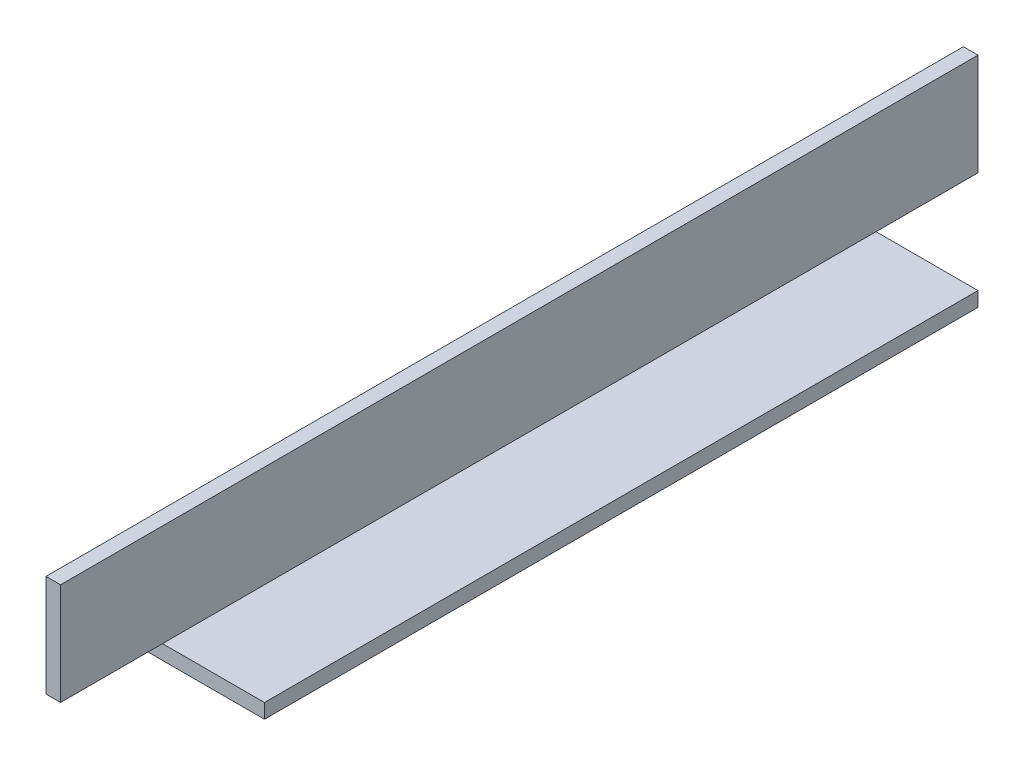
from build123d import *

# Parameters (mm, degrees)
BOSS_EXTRUDE1_DEPTH = 1219.2
FILLET1_R           = 0.4064
SKETCH4_W           = 2238.4
SKETCH4_H           = 103.278519729
CUT_EXTRUDE1_DEPTH  = 60
SKETCH5_W           = 25.4
SKETCH5_H           = 22.23
CUT_EXTRUDE2_DEPTH  = 3.175
SKETCH6_W           = 25.4
SKETCH6_H           = 22.23
CUT_EXTRUDE3_DEPTH  = 3.175
SKETCH7_W           = 1.26890891
SKETCH7_H           = 1.024965533
CUT_EXTRUDE4_DEPTH  = 220


with BuildPart() as part:
    # Sketch3 → Boss-Extrude1 (new, symmetric)
    with BuildSketch(Plane.XY):
        Polygon((3.175, 25.4), (0, 25.4), (0, 0), (25.4, 0), (25.4, 3.175), (3.175, 3.175), align=None)
    extrude(amount=BOSS_EXTRUDE1_DEPTH, both=True)

    # Fillet1
    fillet1_edges = [part.edges().sort_by_distance(p)[0] for p in [
        (3.175, 3.175, 0),
    ]]
    fillet(fillet1_edges, radius=FILLET1_R)

    # Sketch4 → Cut-Extrude1 (cut)
    with BuildSketch(Plane.ZY):
        with Locations((-100, -26.239259864)):
            Rectangle(SKETCH4_W, SKETCH4_H)
    extrude(amount=-CUT_EXTRUDE1_DEPTH, mode=Mode.SUBTRACT)

    # Sketch5 → Cut-Extrude2 (cut)
    with BuildSketch(Plane.XZ):
        with Locations((12.7, 1030.315)):
            Rectangle(SKETCH5_W, SKETCH5_H)
    extrude(amount=-CUT_EXTRUDE2_DEPTH, mode=Mode.SUBTRACT)

    # Sketch6 → Cut-Extrude3 (cut)
    with BuildSketch(Plane.XZ):
        with Locations((12.7, 1208.085)):
            Rectangle(SKETCH6_W, SKETCH6_H)
    extrude(amount=-CUT_EXTRUDE3_DEPTH, mode=Mode.SUBTRACT)

    # Sketch7 → Cut-Extrude4 (cut)
    with BuildSketch(Plane(origin=(0, 0, 1019.2), x_dir=(-1, 0, 0), z_dir=(0, 0, -1))):
        with Locations((-3.809454455, 3.687482767)):
            Rectangle(SKETCH7_W, SKETCH7_H)
    extrude(amount=-CUT_EXTRUDE4_DEPTH, mode=Mode.SUBTRACT)


solid = part.part
